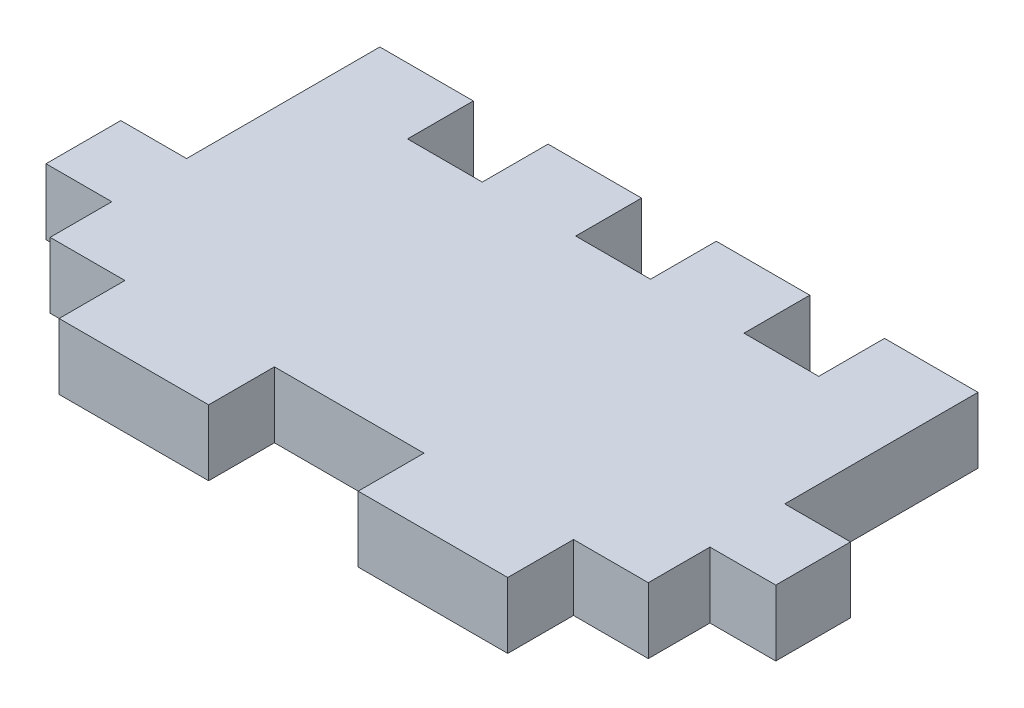
from build123d import *

# Parameters (mm, degrees)
BOSS_EXTRUDE1_DEPTH = 5.588


with BuildPart() as part:
    # Sketch1 → Boss-Extrude1 (new body)
    with BuildSketch(Plane(origin=(0, 0, 0), x_dir=(1, 0, 0), z_dir=(0, 1, 0))):
        Polygon((-17.4625, 16.7939974), (-25.4, 16.7939974), (-25.4, 0.3809974), (-30.988, 0.3809974), (-30.988, -5.9689974), (-25.4, -5.9689974), (-25.4, -11.2059974), (-19.05, -11.2059974), (-19.05, -16.7939974), (-6.35, -16.7939974), (-6.35, -11.2059974), (6.35, -11.2059974), (6.35, -16.7939974), (19.05, -16.7939974), (19.05, -11.2059974), (25.4, -11.2059974), (25.4, -5.9689974), (30.988, -5.9689974), (30.988, 0.3809974), (25.4, 0.3809974), (25.4, 16.7939974), (17.4625, 16.7939974), (17.4625, 11.2059974), (11.1125, 11.2059974), (11.1125, 16.7939974), (3.175, 16.7939974), (3.175, 11.2059974), (-3.175, 11.2059974), (-3.175, 16.7939974), (-11.1125, 16.7939974), (-11.1125, 11.2059974), (-17.4625, 11.2059974), align=None)
    extrude(amount=BOSS_EXTRUDE1_DEPTH)


solid = part.part
